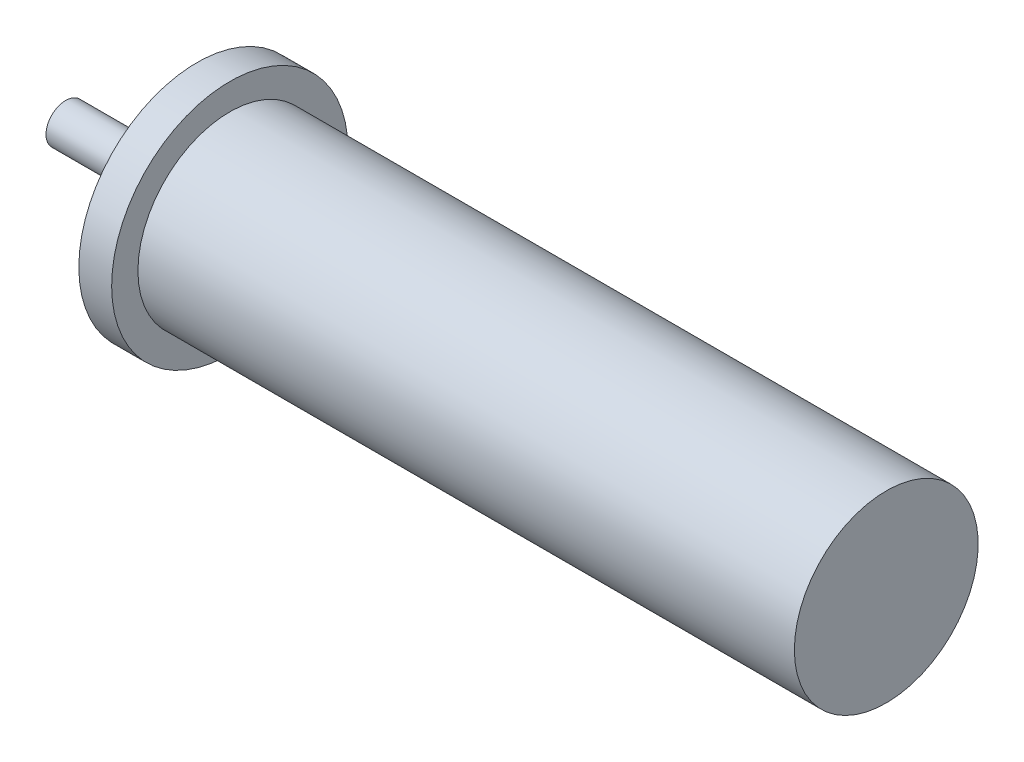
from build123d import *


with BuildPart() as part:
    # Sketch1 → Revolve1 (revolve)
    with BuildSketch(Plane.XY):
        Polygon((0, 3), (0, 0), (125, 0), (125, 14), (25, 14), (25, 18), (20, 18), (20, 11), (18, 11), (18, 3), align=None)
    revolve(axis=Axis((0, 0, 0), (1, 0, 0)))


solid = part.part
